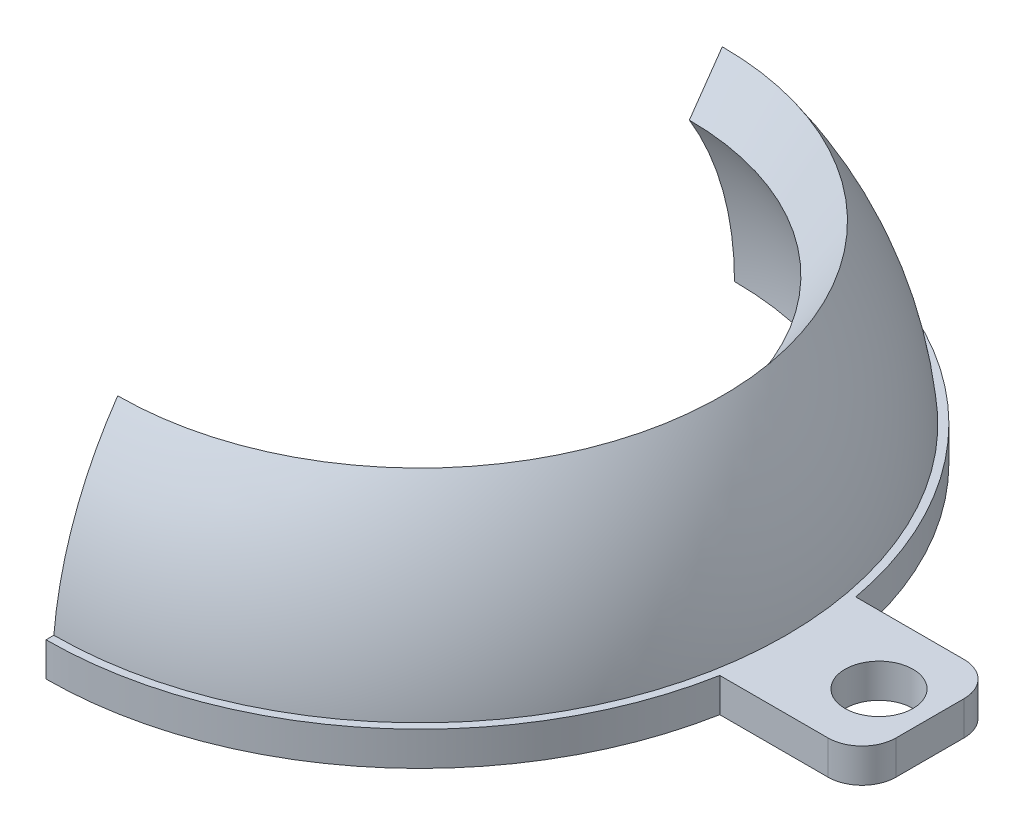
from build123d import *

# Parameters (mm, degrees)
SKETCH2_R           = 18.5
SKETCH2_R_2         = 2
BOSS_EXTRUDE1_DEPTH = 2
SKETCH5_W           = 68.697937928
SKETCH5_H           = 35.271008104
CUT_EXTRUDE1_DEPTH  = 31


with BuildPart() as part:
    # Sketch2 → Boss-Extrude1 (new body)
    with BuildSketch(Plane(origin=(0, 0, 0), x_dir=(1, 0, 0), z_dir=(0, 1, 0))):
        with BuildLine():
            ThreePointArc((30, 2), (29.414213562, 3.414213562), (28, 4))
            Line((28, 4), (21.633307653, 4))
            ThreePointArc((21.633307653, 4), (0, 22), (-21.633307653, 4))
            Line((-21.633307653, 4), (-28, 4))
            ThreePointArc((-28, 4), (-29.414213562, 3.414213562), (-30, 2))
            Line((-30, 2), (-30, -2))
            ThreePointArc((-30, -2), (-29.414213562, -3.414213562), (-28, -4))
            Line((-28, -4), (-21.633307653, -4))
            ThreePointArc((-21.633307653, -4), (0, -22), (21.633307653, -4))
            Line((21.633307653, -4), (28, -4))
            ThreePointArc((28, -4), (29.414213562, -3.414213562), (30, -2))
            Line((30, -2), (30, 2))
        make_face()
        Circle(SKETCH2_R, mode=Mode.SUBTRACT)
        with Locations((27, 0)):
            Circle(SKETCH2_R_2, mode=Mode.SUBTRACT)
        with Locations((-27, 0)):
            Circle(SKETCH2_R_2, mode=Mode.SUBTRACT)
    extrude(amount=BOSS_EXTRUDE1_DEPTH)

    # Sketch4 → Revolve1 (revolve)
    with BuildSketch(Plane.XY):
        with BuildLine():
            Line((-21.633307653, 0), (-18.5, 0))
            ThreePointArc((-18.5, 0), (-17.823557637, 4.956893497), (-15.843698038, 9.551294806))
            Line((-15.843698038, 9.551294806), (-17.782437649, 12.320101917))
            ThreePointArc((-17.782437649, 12.320101917), (-20.648159052, 6.453954428), (-21.633307653, 0))
        make_face()
    revolve(axis=Axis((0, 21.633307653, 0), (0, -1, 0)))

    # Sketch5 → Cut-Extrude1 (cut, through all)
    with BuildSketch(Plane(origin=(0, 0, 0), x_dir=(0, 0, -1), z_dir=(1, 0, 0))):
        Rectangle(SKETCH5_W, SKETCH5_H)
    extrude(amount=-CUT_EXTRUDE1_DEPTH, mode=Mode.SUBTRACT)


solid = part.part
